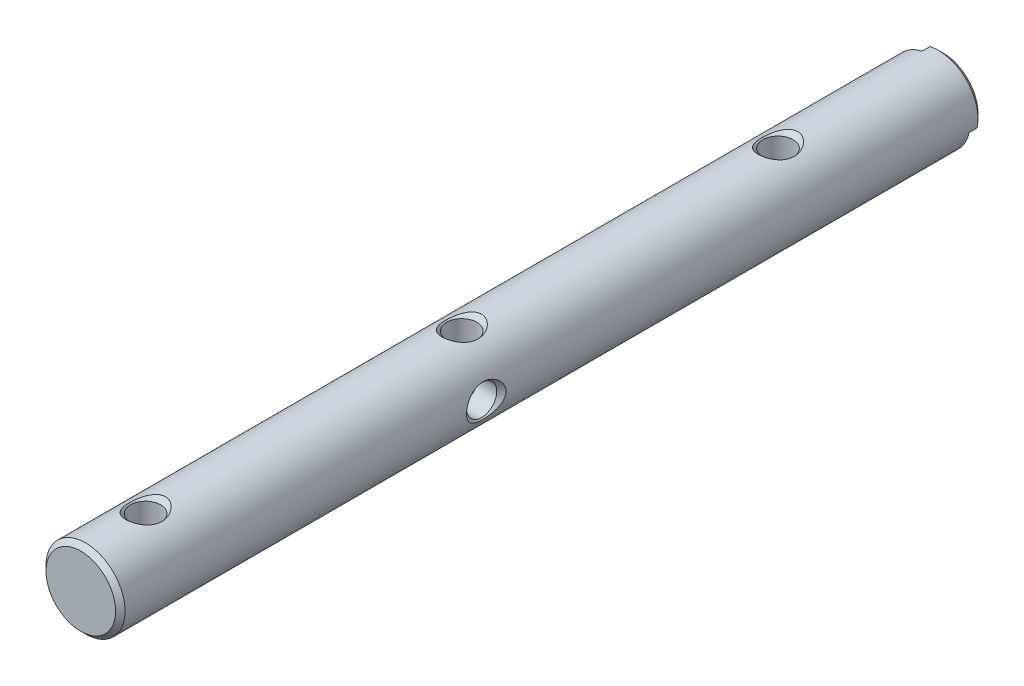
from build123d import *

# Parameters (mm, degrees)
SKETCH1_R                             = 6.35
BOSS_EXTRUDE1_DEPTH                   = 136.525
CHAMFER1_SIZE                         = 0.762
F_11_0_191_DIAMETER_HOLE1_D           = 4.8514
F_11_0_191_DIAMETER_HOLE1_DEPTH       = 12.7
F_11_0_191_DIAMETER_HOLE1_CSINK_D     = 6.35
F_11_0_191_DIAMETER_HOLE1_CSINK_ANGLE = 90
F_11_0_191_DIAMETER_HOLE1_TIP         = 1.457507604
F_8_32_TAPPED_HOLE1_D                 = 3.4544
F_8_32_TAPPED_HOLE1_DEPTH             = 10.7188
F_8_32_TAPPED_HOLE1_TIP               = 1.037806461
F_11_0_191_DIAMETER_HOLE2_D           = 4.8514
F_11_0_191_DIAMETER_HOLE2_DEPTH       = 12.7
F_11_0_191_DIAMETER_HOLE2_CSINK_D     = 6.35
F_11_0_191_DIAMETER_HOLE2_CSINK_ANGLE = 90
F_11_0_191_DIAMETER_HOLE2_TIP         = 1.457507604
BOSS_EXTRUDE2_DEPTH                   = 2.032
CHAMFER2_SIZE                         = 0.762
SKETCH9_R                             = 3.175
CUT_EXTRUDE3_DEPTH                    = 2.54
CUT_EXTRUDE3_TAPER                    = 45
SKETCH10_R                            = 3.175
CUT_EXTRUDE5_DEPTH                    = 2.54
CUT_EXTRUDE5_TAPER                    = 45


with BuildPart() as part:
    # Sketch1 → Boss-Extrude1 (new body)
    with BuildSketch(Plane.XY):
        Circle(SKETCH1_R)
    extrude(amount=BOSS_EXTRUDE1_DEPTH)

    # Chamfer1
    chamfer1_edges = [part.edges().sort_by_distance(p)[0] for p in [
        (-6.35, 0, 136.525),
    ]]
    chamfer(chamfer1_edges, length=CHAMFER1_SIZE)

    # #11 (0.191) Diameter Hole1
    with Locations(Plane(origin=(0, 6.35, 0), x_dir=(-1, 0, 0), z_dir=(0, 1, 0))):
        with Locations((0, 24.511), (0, 75.311), (0, 126.111)):
            CounterSinkHole(F_11_0_191_DIAMETER_HOLE1_D / 2, F_11_0_191_DIAMETER_HOLE1_CSINK_D / 2, depth=F_11_0_191_DIAMETER_HOLE1_DEPTH, counter_sink_angle=F_11_0_191_DIAMETER_HOLE1_CSINK_ANGLE)
            with Locations((0, 0, -(F_11_0_191_DIAMETER_HOLE1_DEPTH + F_11_0_191_DIAMETER_HOLE1_TIP / 2))):  # 118° drill point
                Cone(0, F_11_0_191_DIAMETER_HOLE1_D / 2, F_11_0_191_DIAMETER_HOLE1_TIP, mode=Mode.SUBTRACT)

    # #8-32 Tapped Hole1
    with Locations(Plane(origin=(0, 0, 0), x_dir=(-1, 0, 0), z_dir=(0, 0, -1))):
        with Locations((0, 0)):
            Hole(F_8_32_TAPPED_HOLE1_D / 2, depth=F_8_32_TAPPED_HOLE1_DEPTH)
            with Locations((0, 0, -(F_8_32_TAPPED_HOLE1_DEPTH + F_8_32_TAPPED_HOLE1_TIP / 2))):  # 118° drill point
                Cone(0, F_8_32_TAPPED_HOLE1_D / 2, F_8_32_TAPPED_HOLE1_TIP, mode=Mode.SUBTRACT)

    # #11 (0.191) Diameter Hole2
    with Locations(Plane(origin=(6.35, 0, 0), x_dir=(0, 0, -1), z_dir=(1, 0, 0))):
        with Locations((-77.724, 0)):
            CounterSinkHole(F_11_0_191_DIAMETER_HOLE2_D / 2, F_11_0_191_DIAMETER_HOLE2_CSINK_D / 2, depth=F_11_0_191_DIAMETER_HOLE2_DEPTH, counter_sink_angle=F_11_0_191_DIAMETER_HOLE2_CSINK_ANGLE)
            with Locations((0, 0, -(F_11_0_191_DIAMETER_HOLE2_DEPTH + F_11_0_191_DIAMETER_HOLE2_TIP / 2))):  # 118° drill point
                Cone(0, F_11_0_191_DIAMETER_HOLE2_D / 2, F_11_0_191_DIAMETER_HOLE2_TIP, mode=Mode.SUBTRACT)

    # Sketch8 → Boss-Extrude2 (add)
    with BuildSketch(Plane(origin=(0, 0, 0), x_dir=(-1, 0, 0), z_dir=(0, 0, -1))):
        with BuildLine():
            Line((-6.203852861, -1.354514555), (1.354514555, 6.203852861))
            ThreePointArc((1.354514555, 6.203852861), (-4.490128061, 4.490128061), (-6.203852861, -1.354514555))
        make_face()
    extrude(amount=BOSS_EXTRUDE2_DEPTH)

    # Chamfer2
    chamfer2_edges = [part.edges().sort_by_distance(p)[0] for p in [
        (4.490128061, 4.490128061, -2.032),
    ]]
    chamfer(chamfer2_edges, length=CHAMFER2_SIZE)

    # Sketch9 → Cut-Extrude3 (cut)
    with BuildSketch(Plane(origin=(-6.35, 0, 0), x_dir=(0, 0, -1), z_dir=(1, 0, 0))):
        with Locations((-77.724, 0)):
            Circle(SKETCH9_R)
    extrude(amount=CUT_EXTRUDE3_DEPTH, taper=CUT_EXTRUDE3_TAPER, mode=Mode.SUBTRACT)

    # Sketch10 → Cut-Extrude5 (cut)
    with BuildSketch(Plane(origin=(0, -6.35, 0), x_dir=(-1, 0, 0), z_dir=(0, 1, 0))):
        with Locations((0, 126.111)):
            Circle(SKETCH10_R)
        with Locations((0, 75.311)):
            Circle(SKETCH10_R)
        with Locations((0, 24.511)):
            Circle(SKETCH10_R)
    extrude(amount=CUT_EXTRUDE5_DEPTH, taper=CUT_EXTRUDE5_TAPER, mode=Mode.SUBTRACT)


solid = part.part
